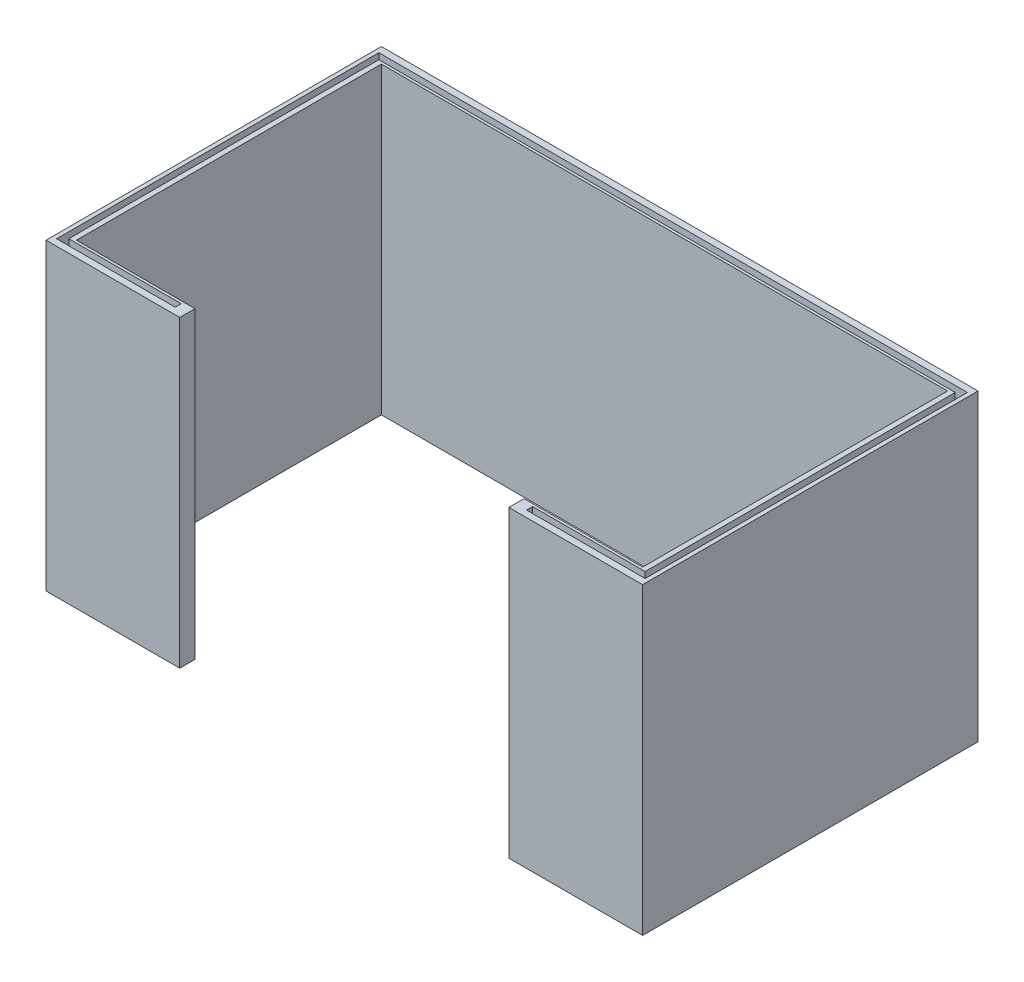
from build123d import *

# Parameters (mm, degrees)
BOSS_EXTRUDE1_DEPTH = 60
CUT_EXTRUDE1_DEPTH  = 5


with BuildPart() as part:
    # Sketch1 → Boss-Extrude1 (new body)
    with BuildSketch(Plane(origin=(0, 0, 0), x_dir=(1, 0, 0), z_dir=(0, 1, 0))):
        Polygon((-32.5, -30.12), (-32.5, -33.12), (-58.915, -33.12), (-58.915, 33.12), (58.915, 33.12), (58.915, -33.12), (32.5, -33.12), (32.5, -30.12), (55.915, -30.12), (55.915, 30.12), (-55.915, 30.12), (-55.915, -30.12), align=None)
    extrude(amount=BOSS_EXTRUDE1_DEPTH)

    # Sketch2 → Cut-Extrude1 (cut)
    with BuildSketch(Plane(origin=(0, 60, 0), x_dir=(1, 0, 0), z_dir=(0, 1, 0))):
        Polygon((-34.7, -30.62), (-34.7, -31.82), (-58.115, -31.82), (-58.115, 31.82), (58.115, 31.82), (58.115, -31.82), (34.7, -31.82), (34.7, -30.62), (56.915, -30.62), (56.915, 30.62), (-56.915, 30.62), (-56.915, -30.62), align=None)
    extrude(amount=-CUT_EXTRUDE1_DEPTH, mode=Mode.SUBTRACT)


solid = part.part
